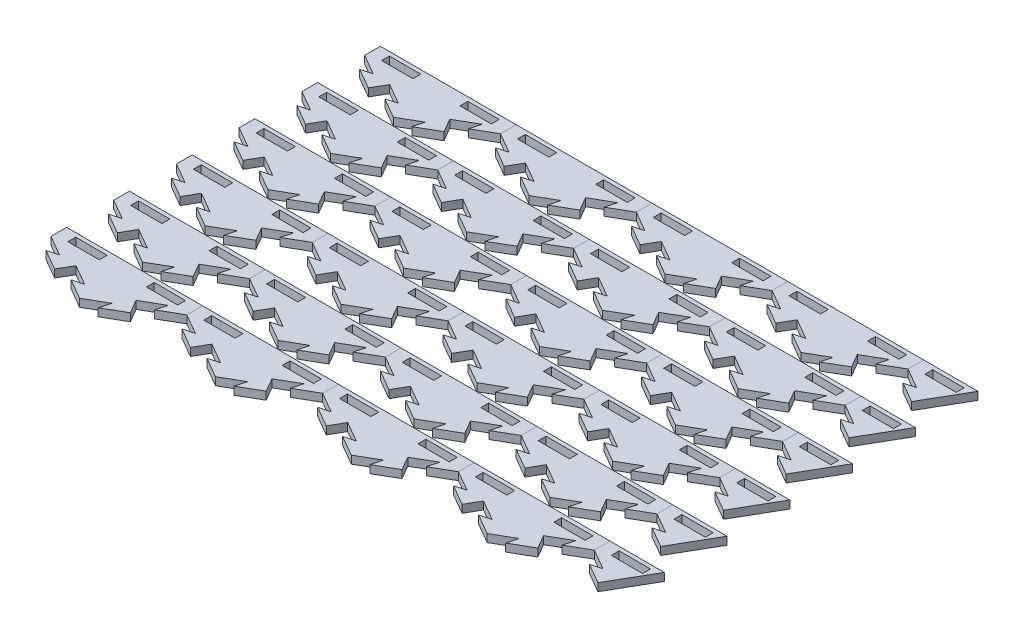
from build123d import *

# Parameters (mm, degrees)
BOSS_EXTRUDE1_DEPTH = 6.35
CUT_EXTRUDE4_DEPTH  = 111.168382488
BOSS_EXTRUDE4_DEPTH = 6.35
CIRPATTERN1_COUNT   = 2
CIRPATTERN1_ANGLE   = 60
SKETCH12_W          = 109.98522628
SKETCH12_H          = 82.55
CUT_EXTRUDE5_DEPTH  = 111.168382488
SKETCH13_W          = 25.4
SKETCH13_H          = 6.35
CUT_EXTRUDE6_DEPTH  = 64.816710194
LPATTERN1_COUNT     = 5
LPATTERN1_PITCH     = 109.985226308
LPATTERN1_2_COUNT   = 2
LPATTERN1_2_PITCH   = 109.985226308
SKETCH14_W          = 25.4
SKETCH14_H          = 6.35
CUT_EXTRUDE7_DEPTH  = 496.991504573
SKETCH15_W          = 43.994090512
SKETCH15_H          = 23.075738686
CUT_EXTRUDE8_DEPTH  = 431.162704792
LPATTERN2_COUNT     = 6
LPATTERN2_PITCH     = 50.8


with BuildPart() as part:
    # Sketch1 → Boss-Extrude1 (new body)
    with BuildSketch(Plane(origin=(0, 0, 0), x_dir=(1, 0, 0), z_dir=(0, 1, 0))):
        Polygon((-54.99261314, 0), (0, -31.75), (54.99261314, 0), (54.99261314, 63.5), (0, 95.25), (-54.99261314, 63.5), align=None)
    extrude(amount=-BOSS_EXTRUDE1_DEPTH)

    # Sketch10 → Cut-Extrude4 (cut, through all)
    with BuildSketch(Plane(origin=(0, 0, 0), x_dir=(1, 0, 0), z_dir=(0, 1, 0))):
        Polygon((-16.497783942, -22.225), (-7.823522628, -19.900738686), (-24.32130657, -10.375738686), (-27.49630657, -15.875), align=None)
    cut_extrude4 = extrude(amount=-CUT_EXTRUDE4_DEPTH, mode=Mode.SUBTRACT)

    # Sketch11 → Boss-Extrude4 (add)
    with BuildSketch(Plane(origin=(0, 0, 0), x_dir=(1, 0, 0), z_dir=(0, 1, 0))):
        Polygon((-27.49630657, -15.875), (-30.67130657, -21.374261314), (-47.169090512, -11.849261314), (-38.494829198, -9.525), align=None)
    boss_extrude4 = extrude(amount=-BOSS_EXTRUDE4_DEPTH)

    # CirPattern1: Cut-Extrude4, Boss-Extrude4 ×2 about axis
    cirpattern1_axis = Axis((0, 0, -31.75), (0, 1, 0))
    add([cut_extrude4.rotate(cirpattern1_axis, i * CIRPATTERN1_ANGLE / (CIRPATTERN1_COUNT - 1)) for i in range(1, CIRPATTERN1_COUNT)], mode=Mode.SUBTRACT)
    add([boss_extrude4.rotate(cirpattern1_axis, i * CIRPATTERN1_ANGLE / (CIRPATTERN1_COUNT - 1)) for i in range(1, CIRPATTERN1_COUNT)])

    # Sketch12 → Cut-Extrude5 (cut, through all)
    with BuildSketch(Plane(origin=(0, 0, 0), x_dir=(1, 0, 0), z_dir=(0, 1, 0))):
        with Locations((0, 53.975)):
            Rectangle(SKETCH12_W, SKETCH12_H)
    extrude(amount=-CUT_EXTRUDE5_DEPTH, mode=Mode.SUBTRACT)

    # Sketch13 → Cut-Extrude6 (cut, through all)
    with BuildSketch(Plane(origin=(0, 0, 0), x_dir=(1, 0, 0), z_dir=(0, 1, 0))):
        with Locations((-31.75, 6.35)):
            Rectangle(SKETCH13_W, SKETCH13_H)
        with Locations((31.75, 6.35)):
            Rectangle(SKETCH13_W, SKETCH13_H)
    extrude(amount=-CUT_EXTRUDE6_DEPTH, mode=Mode.SUBTRACT)


with BuildPart() as lpattern1_1:
    # LPattern1: pattern copy
    add(part.part.moved(Location(Vector(1, 0, 0) * (1 * LPATTERN1_PITCH))))


with BuildPart() as lpattern1_2:
    # LPattern1: pattern copy
    add(part.part.moved(Location(Vector(1, 0, 0) * (2 * LPATTERN1_PITCH))))


with BuildPart() as lpattern1_3:
    # LPattern1: pattern copy
    add(part.part.moved(Location(Vector(1, 0, 0) * (3 * LPATTERN1_PITCH))))


with BuildPart() as lpattern1_4:
    # LPattern1: pattern copy
    add(part.part.moved(Location(Vector(1, 0, 0) * (4 * LPATTERN1_PITCH))))


with BuildPart() as lpattern1_2_1:
    # LPattern1 2: pattern copy
    add(part.part.moved(Location(Vector(-1, 0, 0) * (1 * LPATTERN1_2_PITCH))))


with BuildPart() as cut_extrude7_tool:
    # Sketch14 → Cut-Extrude7 (new, through all)
    # profile 1 of 2: a face of its own
    with BuildSketch(Plane(origin=(0, 0, 0), x_dir=(1, 0, 0), z_dir=(0, 1, 0))):
        Polygon((423.44312129, -22.225), (439.940905232, -31.75), (456.438689174, -22.225), (454.11442786, -30.899261314), (470.612211802, -21.374261314), (464.262211802, -10.375738686), (480.759995744, -0.850738686), (478.43573443, -9.525), (494.933518372, 0), (494.933518372, 12.7), (428.942382604, 12.7), (415.619598662, -10.375738686), (432.117382604, -19.900738686), align=None)
        with Locations((471.690905232, 6.35)):
            Rectangle(SKETCH14_W, SKETCH14_H, mode=Mode.SUBTRACT)
    # profile 2 of 2: a face of its own
    with BuildSketch(Plane(origin=(0, 0, 0), x_dir=(1, 0, 0), z_dir=(0, 1, 0))):
        Polygon((-164.977839448, -31.75), (-109.985226308, -31.75), (-95.81170368, -30.899261314), (-79.313919738, -21.374261314), (-98.98670368, 12.7), (-164.977839448, 12.7), align=None)
    extrude(amount=-CUT_EXTRUDE7_DEPTH)


with BuildPart() as lpattern1_4_1:
    add(lpattern1_4.part)

    # Cut-Extrude7: cut by cut_extrude7_tool
    add(cut_extrude7_tool.part, mode=Mode.SUBTRACT)


with BuildPart() as lpattern1_2_1_1:
    add(lpattern1_2_1.part)

    # Cut-Extrude7: cut by cut_extrude7_tool
    add(cut_extrude7_tool.part, mode=Mode.SUBTRACT)

    # Sketch15 → Cut-Extrude8 (cut, through all)
    with BuildSketch(Plane(origin=(0, 0, 0), x_dir=(1, 0, 0), z_dir=(0, 1, 0))):
        with Locations((-76.989658424, 1.162130657)):
            Rectangle(SKETCH15_W, SKETCH15_H)
    extrude(amount=-CUT_EXTRUDE8_DEPTH, mode=Mode.SUBTRACT)


with BuildPart() as lpattern2_1:
    # LPattern2: pattern copy
    add(lpattern1_4_1.part.moved(Location(Vector(0, 0, 1) * (1 * LPATTERN2_PITCH))))


with BuildPart() as lpattern2_2:
    # LPattern2: pattern copy
    add(lpattern1_4_1.part.moved(Location(Vector(0, 0, 1) * (2 * LPATTERN2_PITCH))))


with BuildPart() as lpattern2_3:
    # LPattern2: pattern copy
    add(lpattern1_4_1.part.moved(Location(Vector(0, 0, 1) * (3 * LPATTERN2_PITCH))))


with BuildPart() as lpattern2_4:
    # LPattern2: pattern copy
    add(lpattern1_4_1.part.moved(Location(Vector(0, 0, 1) * (4 * LPATTERN2_PITCH))))


with BuildPart() as lpattern2_5:
    # LPattern2: pattern copy
    add(lpattern1_4_1.part.moved(Location(Vector(0, 0, 1) * (5 * LPATTERN2_PITCH))))


with BuildPart() as lpattern2_6:
    # LPattern2: pattern copy
    add(lpattern1_3.part.moved(Location(Vector(0, 0, 1) * (1 * LPATTERN2_PITCH))))


with BuildPart() as lpattern2_7:
    # LPattern2: pattern copy
    add(lpattern1_3.part.moved(Location(Vector(0, 0, 1) * (2 * LPATTERN2_PITCH))))


with BuildPart() as lpattern2_8:
    # LPattern2: pattern copy
    add(lpattern1_3.part.moved(Location(Vector(0, 0, 1) * (3 * LPATTERN2_PITCH))))


with BuildPart() as lpattern2_9:
    # LPattern2: pattern copy
    add(lpattern1_3.part.moved(Location(Vector(0, 0, 1) * (4 * LPATTERN2_PITCH))))


with BuildPart() as lpattern2_10:
    # LPattern2: pattern copy
    add(lpattern1_3.part.moved(Location(Vector(0, 0, 1) * (5 * LPATTERN2_PITCH))))


with BuildPart() as lpattern2_11:
    # LPattern2: pattern copy
    add(lpattern1_2.part.moved(Location(Vector(0, 0, 1) * (1 * LPATTERN2_PITCH))))


with BuildPart() as lpattern2_12:
    # LPattern2: pattern copy
    add(lpattern1_2.part.moved(Location(Vector(0, 0, 1) * (2 * LPATTERN2_PITCH))))


with BuildPart() as lpattern2_13:
    # LPattern2: pattern copy
    add(lpattern1_2.part.moved(Location(Vector(0, 0, 1) * (3 * LPATTERN2_PITCH))))


with BuildPart() as lpattern2_14:
    # LPattern2: pattern copy
    add(lpattern1_2.part.moved(Location(Vector(0, 0, 1) * (4 * LPATTERN2_PITCH))))


with BuildPart() as lpattern2_15:
    # LPattern2: pattern copy
    add(lpattern1_2.part.moved(Location(Vector(0, 0, 1) * (5 * LPATTERN2_PITCH))))


with BuildPart() as lpattern2_16:
    # LPattern2: pattern copy
    add(lpattern1_1.part.moved(Location(Vector(0, 0, 1) * (1 * LPATTERN2_PITCH))))


with BuildPart() as lpattern2_17:
    # LPattern2: pattern copy
    add(lpattern1_1.part.moved(Location(Vector(0, 0, 1) * (2 * LPATTERN2_PITCH))))


with BuildPart() as lpattern2_18:
    # LPattern2: pattern copy
    add(lpattern1_1.part.moved(Location(Vector(0, 0, 1) * (3 * LPATTERN2_PITCH))))


with BuildPart() as lpattern2_19:
    # LPattern2: pattern copy
    add(lpattern1_1.part.moved(Location(Vector(0, 0, 1) * (4 * LPATTERN2_PITCH))))


with BuildPart() as lpattern2_20:
    # LPattern2: pattern copy
    add(lpattern1_1.part.moved(Location(Vector(0, 0, 1) * (5 * LPATTERN2_PITCH))))


with BuildPart() as lpattern2_21:
    # LPattern2: pattern copy
    add(part.part.moved(Location(Vector(0, 0, 1) * (1 * LPATTERN2_PITCH))))


with BuildPart() as lpattern2_22:
    # LPattern2: pattern copy
    add(part.part.moved(Location(Vector(0, 0, 1) * (2 * LPATTERN2_PITCH))))


with BuildPart() as lpattern2_23:
    # LPattern2: pattern copy
    add(part.part.moved(Location(Vector(0, 0, 1) * (3 * LPATTERN2_PITCH))))


with BuildPart() as lpattern2_24:
    # LPattern2: pattern copy
    add(part.part.moved(Location(Vector(0, 0, 1) * (4 * LPATTERN2_PITCH))))


with BuildPart() as lpattern2_25:
    # LPattern2: pattern copy
    add(part.part.moved(Location(Vector(0, 0, 1) * (5 * LPATTERN2_PITCH))))


solid = Compound([part.part, lpattern1_1.part, lpattern1_2.part, lpattern1_3.part, lpattern1_4_1.part, lpattern2_1.part, lpattern2_2.part, lpattern2_3.part, lpattern2_4.part, lpattern2_5.part, lpattern2_6.part, lpattern2_7.part, lpattern2_8.part, lpattern2_9.part, lpattern2_10.part, lpattern2_11.part, lpattern2_12.part, lpattern2_13.part, lpattern2_14.part, lpattern2_15.part, lpattern2_16.part, lpattern2_17.part, lpattern2_18.part, lpattern2_19.part, lpattern2_20.part, lpattern2_21.part, lpattern2_22.part, lpattern2_23.part, lpattern2_24.part, lpattern2_25.part])
